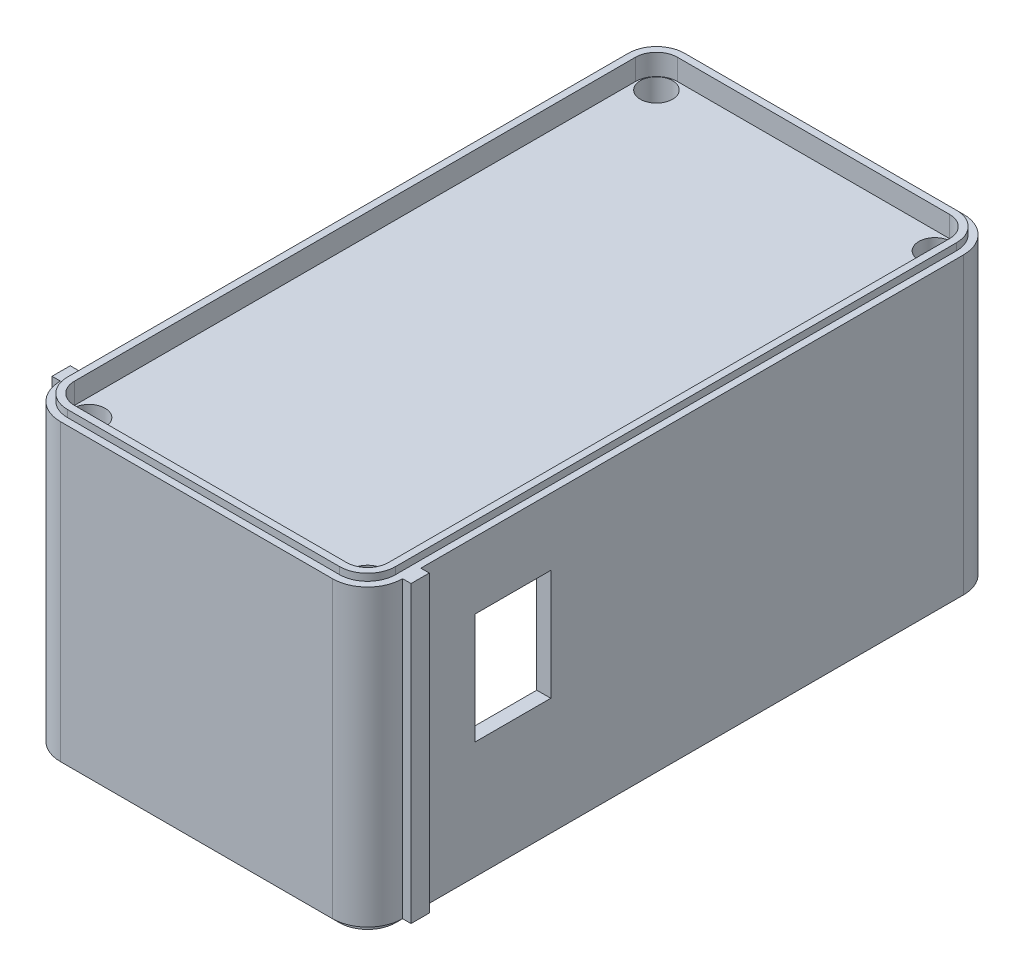
from build123d import *

# Parameters (mm, degrees)
SALIENTE_EXTRUIR1_DEPTH           = 10.5
CORTAR_EXTRUIR2_REACH             = 29.665
CROQUIS1_6_R                      = 1.15
CORTAR_EXTRUIR2_DIRECTION_2_REACH = 29.665
VACIADO3_T                        = -1
VACIADO3_THICKNESS_2_DEPTH        = 1
SALIENTE_EXTRUIR2_START           = 10.5
SALIENTE_EXTRUIR2_DEPTH           = 0.5
CROQUIS4_R                        = 1.15
CORTAR_EXTRUIR3_DEPTH             = 1
CROQUIS5_W                        = 6.4
CROQUIS5_H                        = 3.4
CORTAR_EXTRUIR4_DEPTH             = 0.8
CHAFL_N2_SIZE                     = 0.5
SALIENTE_EXTRUIR3_START           = -0.8
CROQUIS5_3_W                      = 6.2
CROQUIS5_3_H                      = 3.2
CROQUIS5_3_W_2                    = 5.6
CROQUIS5_3_H_2                    = 2.6
SALIENTE_EXTRUIR3_DEPTH           = 1.5
CROQUIS5_4_W                      = 5.4
CROQUIS5_4_H                      = 7.9
CORTAR_EXTRUIR5_DEPTH             = 35.965840473
SALIENTE_EXTRUIR4_START           = -0.8
CROQUIS5_6_R                      = 0.3
SALIENTE_EXTRUIR4_DEPTH           = 1.4
CROQUIS5_7_W                      = 1.3
CROQUIS5_7_H                      = 21
SALIENTE_EXTRUIR5_DEPTH           = 0.6


with BuildPart() as part:
    # Croquis1 → Saliente-Extruir1 (new, symmetric)
    with BuildSketch(Plane(origin=(0, 0, 0), x_dir=(1, 0, 0), z_dir=(0, 1, 0))):
        with BuildLine():
            Line((-9.7, 22.5), (9.7, 22.5))
            ThreePointArc((9.7, 22.5), (11.467766953, 21.767766953), (12.2, 20))
            Line((12.2, 20), (12.2, -20))
            ThreePointArc((12.2, -20), (11.467766953, -21.767766953), (9.7, -22.5))
            Line((9.7, -22.5), (-9.7, -22.5))
            ThreePointArc((-9.7, -22.5), (-11.467766953, -21.767766953), (-12.2, -20))
            Line((-12.2, -20), (-12.2, 20))
            ThreePointArc((-12.2, 20), (-11.467766953, 21.767766953), (-9.7, 22.5))
        make_face()
    extrude(amount=SALIENTE_EXTRUIR1_DEPTH, both=True)

    # Croquis1_6 → Cortar-Extruir2 (cut, up to next)
    with BuildSketch(Plane(origin=(0, 0, 0), x_dir=(1, 0, 0), z_dir=(0, 1, 0)), mode=Mode.PRIVATE) as cortar_extruir2_sk1:
        with Locations(Location((-9.93, 20.23, 0), (0, 0, 270))):
            Circle(CROQUIS1_6_R)
    cortar_extruir2_tool1 = extrude(cortar_extruir2_sk1.sketch, amount=-CORTAR_EXTRUIR2_REACH, mode=Mode.PRIVATE) & part.part
    # Croquis1_6 → Cortar-Extruir2 (cut, up to next)
    with BuildSketch(Plane(origin=(0, 0, 0), x_dir=(1, 0, 0), z_dir=(0, 1, 0)), mode=Mode.PRIVATE) as cortar_extruir2_sk2:
        with Locations(Location((9.93, 20.23, 0), (0, 0, 270))):
            Circle(CROQUIS1_6_R)
    cortar_extruir2_tool2 = extrude(cortar_extruir2_sk2.sketch, amount=-CORTAR_EXTRUIR2_REACH, mode=Mode.PRIVATE) & part.part
    # Croquis1_6 → Cortar-Extruir2 (cut, up to next)
    with BuildSketch(Plane(origin=(0, 0, 0), x_dir=(1, 0, 0), z_dir=(0, 1, 0)), mode=Mode.PRIVATE) as cortar_extruir2_sk3:
        with Locations(Location((-9.93, -20.23, 0), (0, 0, 270))):
            Circle(CROQUIS1_6_R)
    cortar_extruir2_tool3 = extrude(cortar_extruir2_sk3.sketch, amount=-CORTAR_EXTRUIR2_REACH, mode=Mode.PRIVATE) & part.part
    # Croquis1_6 → Cortar-Extruir2 (cut, up to next)
    with BuildSketch(Plane(origin=(0, 0, 0), x_dir=(1, 0, 0), z_dir=(0, 1, 0)), mode=Mode.PRIVATE) as cortar_extruir2_sk4:
        with Locations(Location((9.93, -20.23, 0), (0, 0, 270))):
            Circle(CROQUIS1_6_R)
    cortar_extruir2_tool4 = extrude(cortar_extruir2_sk4.sketch, amount=-CORTAR_EXTRUIR2_REACH, mode=Mode.PRIVATE) & part.part
    add(cortar_extruir2_tool1.solids().sort_by_distance((-9.93, 0, -20.23))[0], mode=Mode.SUBTRACT)
    add(cortar_extruir2_tool2.solids().sort_by_distance((9.93, 0, -20.23))[0], mode=Mode.SUBTRACT)
    add(cortar_extruir2_tool3.solids().sort_by_distance((-9.93, 0, 20.23))[0], mode=Mode.SUBTRACT)
    add(cortar_extruir2_tool4.solids().sort_by_distance((9.93, 0, 20.23))[0], mode=Mode.SUBTRACT)

    # Croquis1_6 → Cortar-Extruir2 direction 2 (cut, up to next)
    with BuildSketch(Plane(origin=(0, 0, 0), x_dir=(1, 0, 0), z_dir=(0, 1, 0)), mode=Mode.PRIVATE) as cortar_extruir2_direction_2_sk1:
        with Locations(Location((-9.93, 20.23, 0), (0, 0, 270))):
            Circle(CROQUIS1_6_R)
    cortar_extruir2_direction_2_tool1 = extrude(cortar_extruir2_direction_2_sk1.sketch, amount=CORTAR_EXTRUIR2_DIRECTION_2_REACH, mode=Mode.PRIVATE) & part.part
    # Croquis1_6 → Cortar-Extruir2 direction 2 (cut, up to next)
    with BuildSketch(Plane(origin=(0, 0, 0), x_dir=(1, 0, 0), z_dir=(0, 1, 0)), mode=Mode.PRIVATE) as cortar_extruir2_direction_2_sk2:
        with Locations(Location((9.93, 20.23, 0), (0, 0, 270))):
            Circle(CROQUIS1_6_R)
    cortar_extruir2_direction_2_tool2 = extrude(cortar_extruir2_direction_2_sk2.sketch, amount=CORTAR_EXTRUIR2_DIRECTION_2_REACH, mode=Mode.PRIVATE) & part.part
    # Croquis1_6 → Cortar-Extruir2 direction 2 (cut, up to next)
    with BuildSketch(Plane(origin=(0, 0, 0), x_dir=(1, 0, 0), z_dir=(0, 1, 0)), mode=Mode.PRIVATE) as cortar_extruir2_direction_2_sk3:
        with Locations(Location((-9.93, -20.23, 0), (0, 0, 270))):
            Circle(CROQUIS1_6_R)
    cortar_extruir2_direction_2_tool3 = extrude(cortar_extruir2_direction_2_sk3.sketch, amount=CORTAR_EXTRUIR2_DIRECTION_2_REACH, mode=Mode.PRIVATE) & part.part
    # Croquis1_6 → Cortar-Extruir2 direction 2 (cut, up to next)
    with BuildSketch(Plane(origin=(0, 0, 0), x_dir=(1, 0, 0), z_dir=(0, 1, 0)), mode=Mode.PRIVATE) as cortar_extruir2_direction_2_sk4:
        with Locations(Location((9.93, -20.23, 0), (0, 0, 270))):
            Circle(CROQUIS1_6_R)
    cortar_extruir2_direction_2_tool4 = extrude(cortar_extruir2_direction_2_sk4.sketch, amount=CORTAR_EXTRUIR2_DIRECTION_2_REACH, mode=Mode.PRIVATE) & part.part
    add(cortar_extruir2_direction_2_tool1.solids().sort_by_distance((-9.93, 0, -20.23))[0], mode=Mode.SUBTRACT)
    add(cortar_extruir2_direction_2_tool2.solids().sort_by_distance((9.93, 0, -20.23))[0], mode=Mode.SUBTRACT)
    add(cortar_extruir2_direction_2_tool3.solids().sort_by_distance((-9.93, 0, 20.23))[0], mode=Mode.SUBTRACT)
    add(cortar_extruir2_direction_2_tool4.solids().sort_by_distance((9.93, 0, 20.23))[0], mode=Mode.SUBTRACT)

    # Vaciado3
    vaciado3_openings = [part.faces().sort_by_distance(p)[0] for p in [
        (0, -10.5, 0),
    ]]
    offset(amount=VACIADO3_T, openings=vaciado3_openings, kind=Kind.INTERSECTION)

    # Vaciado3 thickness 2 face (on inner face of the shell) → Vaciado3 thickness 2 (add)
    with BuildSketch(Plane.ZX.offset(9.5)):
        with BuildLine():
            Line((-21.5, -8.195180125), (-21.5, 8.195180125))
            ThreePointArc((-21.5, 8.195180125), (-18.70972042, 8.40972042), (-18.495180125, 11.2))
            Line((-18.495180125, 11.2), (18.495180125, 11.2))
            ThreePointArc((18.495180125, 11.2), (18.70972042, 8.40972042), (21.5, 8.195180125))
            Line((21.5, 8.195180125), (21.5, -8.195180125))
            ThreePointArc((21.5, -8.195180125), (18.70972042, -8.40972042), (18.495180125, -11.2))
            Line((18.495180125, -11.2), (-18.495180125, -11.2))
            ThreePointArc((-18.495180125, -11.2), (-18.70972042, -8.40972042), (-21.5, -8.195180125))
        make_face()
    extrude(amount=-VACIADO3_THICKNESS_2_DEPTH)

    # Croquis1_4 → Saliente-Extruir2 (add)
    with BuildSketch(Plane(origin=(0, 0, 0), x_dir=(1, 0, 0), z_dir=(0, 1, 0)).offset(SALIENTE_EXTRUIR2_START)):
        with BuildLine():
            ThreePointArc((9.7, 22), (11.114213562, 21.414213562), (11.7, 20))
            Line((11.7, 20), (11.7, -20))
            ThreePointArc((11.7, -20), (11.114213562, -21.414213562), (9.7, -22))
            Line((9.7, -22), (-9.7, -22))
            ThreePointArc((-9.7, -22), (-11.114213562, -21.414213562), (-11.7, -20))
            Line((-11.7, -20), (-11.7, 20))
            ThreePointArc((-11.7, 20), (-11.114213562, 21.414213562), (-9.7, 22))
            Line((-9.7, 22), (9.7, 22))
        make_face()
        with BuildLine():
            ThreePointArc((-9.7, 21.5), (-10.760660172, 21.060660172), (-11.2, 20))
            Line((-11.2, 20), (-11.2, -20))
            ThreePointArc((-11.2, -20), (-10.760660172, -21.060660172), (-9.7, -21.5))
            Line((-9.7, -21.5), (9.7, -21.5))
            ThreePointArc((9.7, -21.5), (10.760660172, -21.060660172), (11.2, -20))
            Line((11.2, -20), (11.2, 20))
            ThreePointArc((11.2, 20), (10.760660172, 21.060660172), (9.7, 21.5))
            Line((9.7, 21.5), (-9.7, 21.5))
        make_face(mode=Mode.SUBTRACT)
    saliente_extruir2 = extrude(amount=SALIENTE_EXTRUIR2_DEPTH)

    # Simetría3: Saliente-Extruir2 across plane
    add(saliente_extruir2.mirror(Plane.ZX))

    # Croquis4 → Cortar-Extruir3 (cut)
    with BuildSketch(Plane(origin=(0, 10.5, 0), x_dir=(1, 0, 0), z_dir=(0, 1, 0))):
        with BuildLine():
            Line((11.2, -20), (11.2, 20))
            ThreePointArc((11.2, 20), (10.760660172, 21.060660172), (9.7, 21.5))
            Line((9.7, 21.5), (-9.7, 21.5))
            ThreePointArc((-9.7, 21.5), (-10.760660172, 21.060660172), (-11.2, 20))
            Line((-11.2, 20), (-11.2, -20))
            ThreePointArc((-11.2, -20), (-10.760660172, -21.060660172), (-9.7, -21.5))
            Line((-9.7, -21.5), (9.7, -21.5))
            ThreePointArc((9.7, -21.5), (10.760660172, -21.060660172), (11.2, -20))
        make_face()
        with Locations(Location((-9.93, -20.23, 0), (0, 0, 270))):
            Circle(CROQUIS4_R, mode=Mode.SUBTRACT)
        with Locations(Location((9.93, -20.23, 0), (0, 0, 270))):
            Circle(CROQUIS4_R, mode=Mode.SUBTRACT)
        with Locations(Location((-9.93, 20.23, 0), (0, 0, 270))):
            Circle(CROQUIS4_R, mode=Mode.SUBTRACT)
        with Locations(Location((9.93, 20.23, 0), (0, 0, 270))):
            Circle(CROQUIS4_R, mode=Mode.SUBTRACT)
    extrude(amount=-CORTAR_EXTRUIR3_DEPTH, mode=Mode.SUBTRACT)

    # Croquis5 → Cortar-Extruir4 (cut)
    with BuildSketch(Plane.ZY.offset(12.2)):
        with Locations((-4.9, -3)):
            Rectangle(CROQUIS5_W, CROQUIS5_H)
    extrude(amount=-CORTAR_EXTRUIR4_DEPTH, mode=Mode.SUBTRACT)

    # Chaflán2
    chafl_n2_edges = [part.edges().sort_by_distance(p)[0] for p in [
        (-12.2, -4.7, -4.9),
        (-12.2, -3, -8.1),
        (-12.2, -3, -1.7),
        (-12.2, -1.3, -4.9),
    ]]
    chamfer(chafl_n2_edges, length=CHAFL_N2_SIZE)

    # Croquis5_4 → Cortar-Extruir5 (cut, through all)
    with BuildSketch(Plane.ZY.offset(12.2)):
        with Locations((12.135332852, 1.782001246)):
            Rectangle(CROQUIS5_4_W, CROQUIS5_4_H)
    extrude(amount=-CORTAR_EXTRUIR5_DEPTH, mode=Mode.SUBTRACT)


with BuildPart() as body_2:
    # Croquis5_3 → Saliente-Extruir3 (new body)
    with BuildSketch(Plane.ZY.offset(12.2).offset(SALIENTE_EXTRUIR3_START)):
        with Locations((-4.9, -3)):
            Rectangle(CROQUIS5_3_W, CROQUIS5_3_H)
        with Locations((-4.9, -3)):
            Rectangle(CROQUIS5_3_W_2, CROQUIS5_3_H_2, mode=Mode.SUBTRACT)
    extrude(amount=SALIENTE_EXTRUIR3_DEPTH)


    add(part.part)  # Saliente-Extruir4 merges part
    # Croquis5_6 → Saliente-Extruir4 (add)
    with BuildSketch(Plane.ZY.offset(12.2).offset(SALIENTE_EXTRUIR4_START)):
        with Locations(Location((-6.9, -3, 0), (0, 0, 180))):
            Circle(CROQUIS5_6_R)
        with Locations(Location((-4.9, -3, 0), (0, 0, 180))):
            Circle(CROQUIS5_6_R)
        with Locations(Location((-2.9, -3, 0), (0, 0, 180))):
            Circle(CROQUIS5_6_R)
    extrude(amount=SALIENTE_EXTRUIR4_DEPTH)

    # Croquis5_7 → Saliente-Extruir5 (add)
    with BuildSketch(Plane.ZY.offset(12.2)):
        with Locations((19.35, 0)):
            Rectangle(CROQUIS5_7_W, CROQUIS5_7_H)
    saliente_extruir5 = extrude(amount=SALIENTE_EXTRUIR5_DEPTH)

    # Simetría4: Saliente-Extruir5 across plane
    add(saliente_extruir5.mirror(Plane(origin=(0, 0, 0), x_dir=(0, 0, 1), z_dir=(1, 0, 0))))


solid = body_2.part
